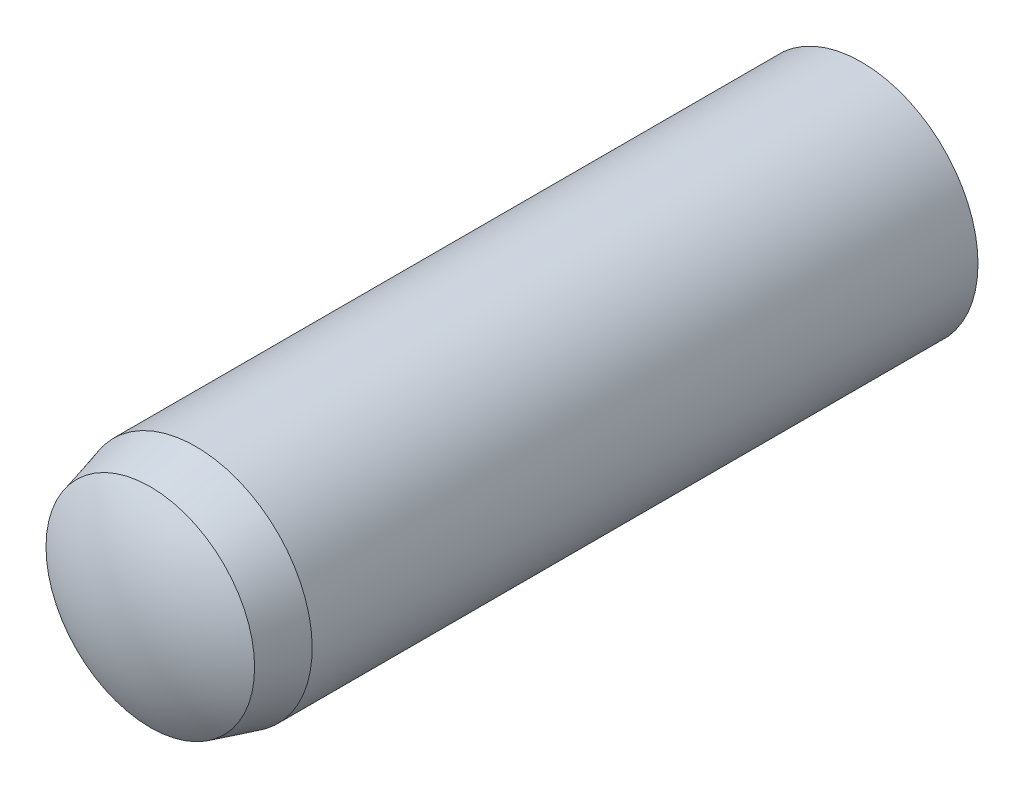
from build123d import *


with BuildPart() as part:
    # Sketch3 → Revolve1 (revolve)
    with BuildSketch(Plane(origin=(0, 0, 0), x_dir=(0, 0, -1), z_dir=(1, 0, 0))):
        with BuildLine():
            Line((-10, 0), (10, 0))
            ThreePointArc((10, 0), (9.770153254, 1.566045976), (9.1, 3))
            Line((9.1, 3), (-8.05, 3))
            Line((-8.05, 3), (-9.22, 2.686499445))
            ThreePointArc((-9.22, 2.686499445), (-9.801055079, 1.398720779), (-10, 0))
        make_face()
    revolve(axis=Axis((0, 0, 10), (0, 0, -1)))


solid = part.part
